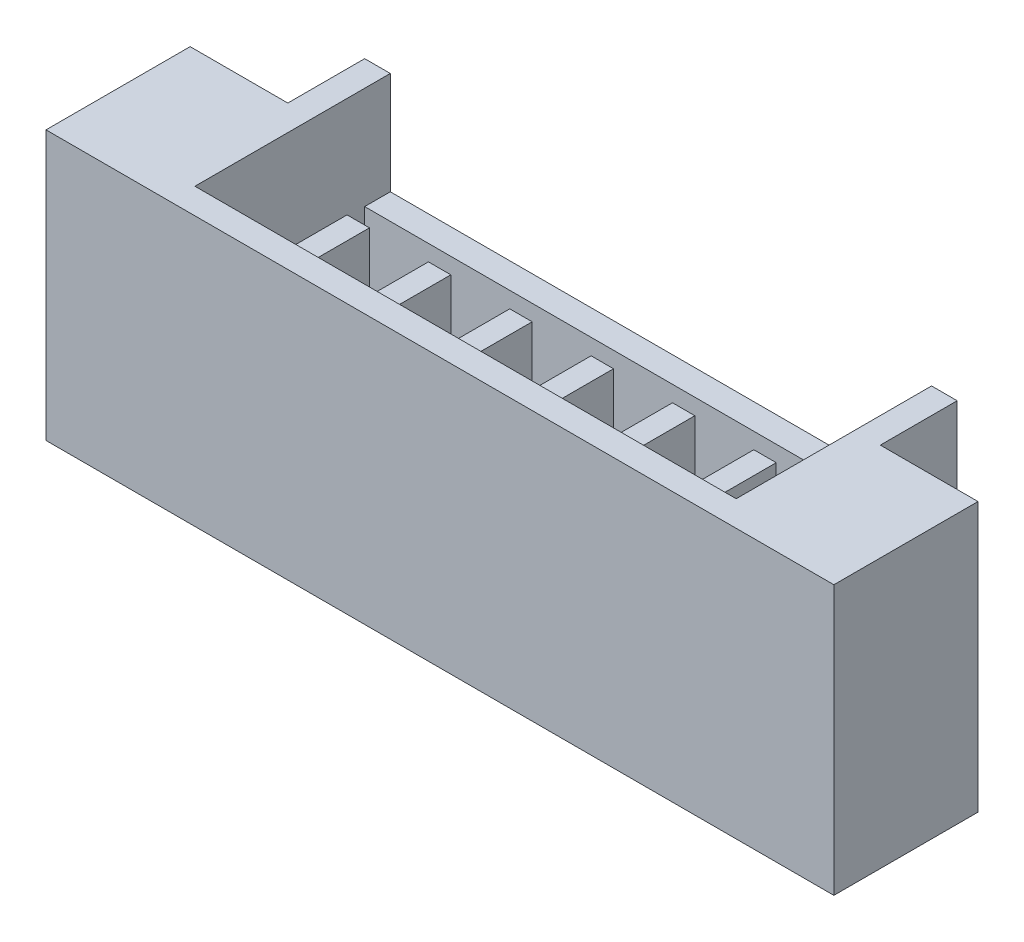
from build123d import *

# Parameters (mm, degrees)
SKETCH1_W           = 1.525
SKETCH1_H           = 2.25
SKETCH1_W_2         = 9.25
SKETCH1_H_2         = 1.2
BOSS_EXTRUDE1_DEPTH = 4.2
SKETCH2_W           = 8.45
SKETCH2_H           = 2.65
CUT_EXTRUDE1_DEPTH  = 3.2
SKETCH3_W           = 8.45
SKETCH3_H           = 0.4
CUT_EXTRUDE2_DEPTH  = 1.6
SKETCH4_W           = 0.35
SKETCH4_H           = 1
BOSS_EXTRUDE2_DEPTH = 2.5


with BuildPart() as part:
    # Sketch1 → Boss-Extrude1 (new body)
    with BuildSketch(Plane(origin=(0, 0, 0), x_dir=(1, 0, 0), z_dir=(0, 1, 0))):
        with Locations((-5.3875, -0.6)):
            Rectangle(SKETCH1_W, SKETCH1_H)
        with Locations((0, 1.125)):
            Rectangle(SKETCH1_W_2, SKETCH1_H_2)
        with Locations((0, -0.6)):
            Rectangle(SKETCH1_W_2, SKETCH1_H)
        with Locations((5.3875, -0.6)):
            Rectangle(SKETCH1_W, SKETCH1_H)
    extrude(amount=BOSS_EXTRUDE1_DEPTH)

    # Sketch2 → Cut-Extrude1 (cut)
    with BuildSketch(Plane(origin=(0, 4.2, 0), x_dir=(1, 0, 0), z_dir=(0, 1, 0))):
        Rectangle(SKETCH2_W, SKETCH2_H)
    extrude(amount=-CUT_EXTRUDE1_DEPTH, mode=Mode.SUBTRACT)

    # Sketch3 → Cut-Extrude2 (cut)
    with BuildSketch(Plane(origin=(0, 4.2, 0), x_dir=(1, 0, 0), z_dir=(0, 1, 0))):
        with Locations((0, 1.525)):
            Rectangle(SKETCH3_W, SKETCH3_H)
    extrude(amount=-CUT_EXTRUDE2_DEPTH, mode=Mode.SUBTRACT)

    # Sketch4 → Boss-Extrude2 (add)
    with BuildSketch(Plane(origin=(0, 1, 0), x_dir=(1, 0, 0), z_dir=(0, 1, 0))):
        with Locations((0.635, -0.325)):
            Rectangle(SKETCH4_W, SKETCH4_H)
        with Locations((-0.635, -0.325)):
            Rectangle(SKETCH4_W, SKETCH4_H)
        with Locations((1.905, -0.325)):
            Rectangle(SKETCH4_W, SKETCH4_H)
        with Locations((3.175, -0.325)):
            Rectangle(SKETCH4_W, SKETCH4_H)
        with Locations((-3.175, -0.325)):
            Rectangle(SKETCH4_W, SKETCH4_H)
        with Locations((-1.905, -0.325)):
            Rectangle(SKETCH4_W, SKETCH4_H)
    extrude(amount=BOSS_EXTRUDE2_DEPTH)


solid = part.part
